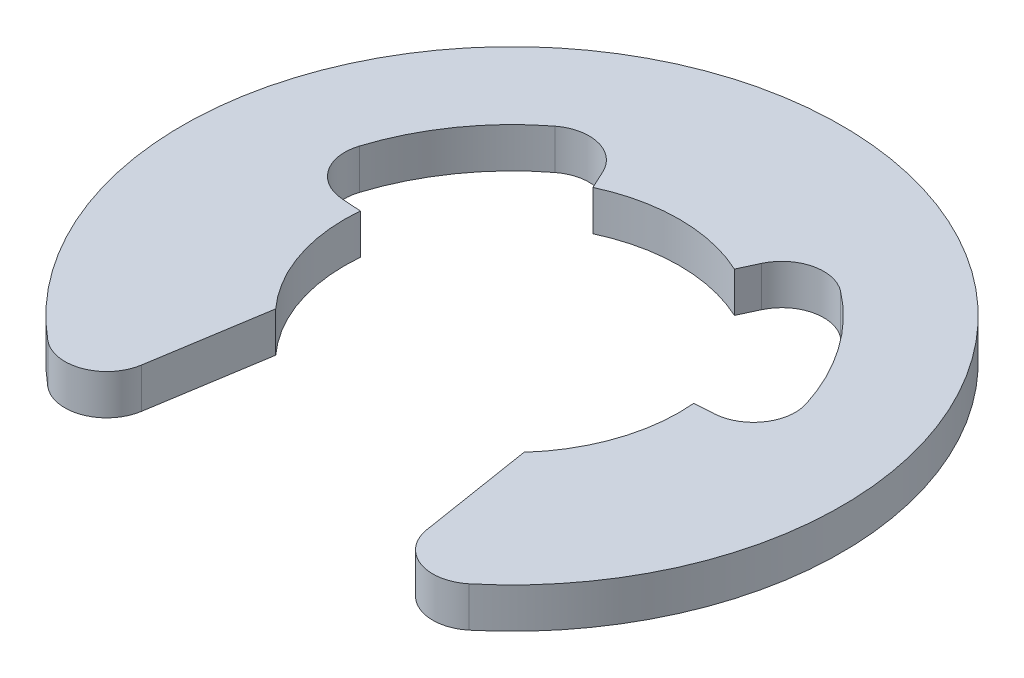
from build123d import *

# Parameters (mm, degrees)
EXTRUDE1_DEPTH = 1.2


with BuildPart() as part:
    # Sketch1 → Extrude1 (new body)
    with BuildSketch(Plane(origin=(0, 0, 0), x_dir=(1, 0, 0), z_dir=(0, 1, 0))):
        with BuildLine():
            Line((2.113091309, 4.531538935), (2.371939111, 5.086639839))
            ThreePointArc((2.371939111, 5.086639839), (3.208308367, 5.77268928), (4.266742072, 5.549316362))
            ThreePointArc((4.266742072, 5.549316362), (5.73406431, 4.015035054), (6.673963371, 2.111448062))
            ThreePointArc((6.673963371, 2.111448062), (6.515398476, 1.030863961), (5.568082875, 0.487358691))
            Line((5.568082875, 0.487358691), (4.979992479, 0.446849981))
            ThreePointArc((4.979992479, 0.446849981), (4.742221478, -1.58471936), (3.710828514, -3.351082175))
            Line((3.710828514, -3.351082175), (4.262184676, -6.810891939))
            ThreePointArc((4.262184676, -6.810891939), (5.05662557, -7.784180304), (6.29553407, -7.575536336))
            ThreePointArc((6.29553407, -7.575536336), (0, 9.85), (-6.29553407, -7.575536336))
            ThreePointArc((-6.29553407, -7.575536336), (-5.05662557, -7.784180304), (-4.262184676, -6.810891939))
            Line((-4.262184676, -6.810891939), (-3.710828514, -3.351082175))
            ThreePointArc((-3.710828514, -3.351082175), (-4.742221478, -1.58471936), (-4.979992479, 0.446849981))
            Line((-4.979992479, 0.446849981), (-5.568082875, 0.487358691))
            ThreePointArc((-5.568082875, 0.487358691), (-6.515398476, 1.030863961), (-6.673963371, 2.111448062))
            ThreePointArc((-6.673963371, 2.111448062), (-5.73406431, 4.015035054), (-4.266742072, 5.549316362))
            ThreePointArc((-4.266742072, 5.549316362), (-3.208308367, 5.77268928), (-2.371939111, 5.086639839))
            Line((-2.371939111, 5.086639839), (-2.113091309, 4.531538935))
            ThreePointArc((-2.113091309, 4.531538935), (0, 5), (2.113091309, 4.531538935))
        make_face()
    extrude(amount=EXTRUDE1_DEPTH)


solid = part.part
